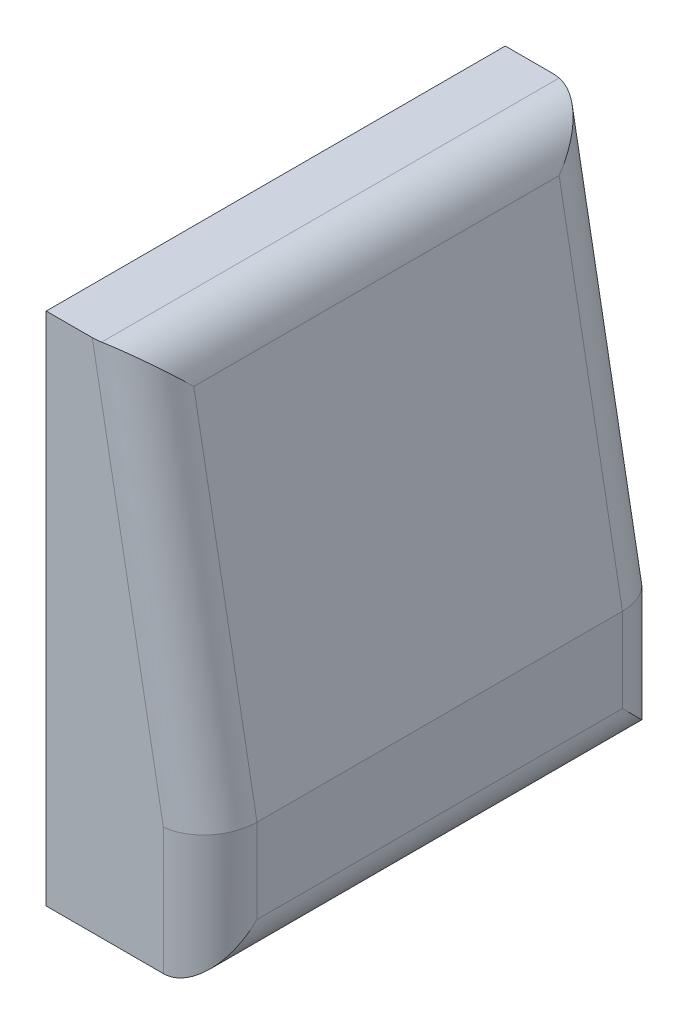
from build123d import *

# Parameters (mm, degrees)
BOSS_EXTRUDE1_DEPTH = 490
FILLET1_R           = 100


with BuildPart() as part:
    # Sketch1 → Boss-Extrude1 (new body, symmetric)
    with BuildSketch(Plane.XY):
        Polygon((0, 1100), (0, 0), (350, 0), (350, 280), (200, 1100), align=None)
    extrude(amount=BOSS_EXTRUDE1_DEPTH, both=True)

    # Fillet1
    fillet1_edges = [part.edges().sort_by_distance(p)[0] for p in [
        (350, 140, 490),
        (275, 690, 490),
        (275, 690, -490),
        (350, 140, -490),
        (200, 1100, 0),
        (350, 0, 0),
    ]]
    fillet(fillet1_edges, radius=FILLET1_R)


solid = part.part
